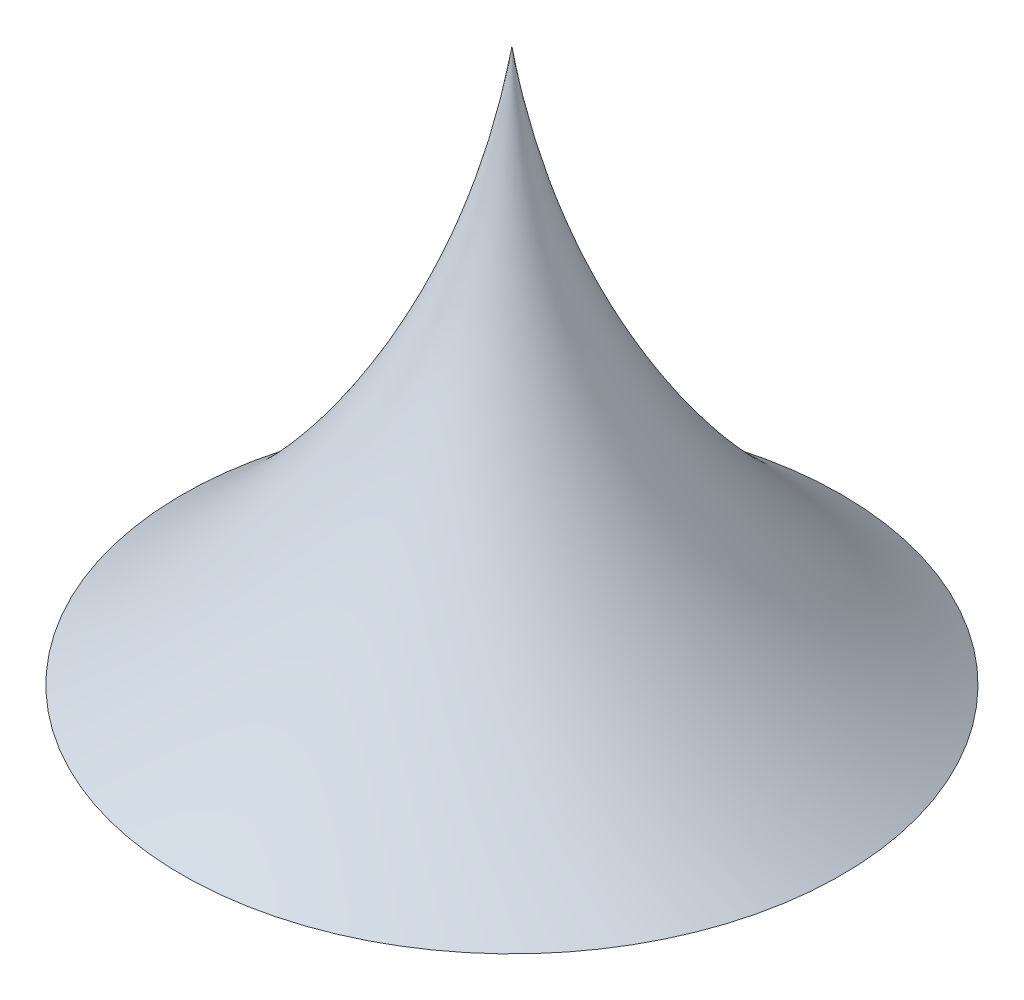
from build123d import *

# Parameters (mm, degrees)
SKETCH4_W               = 141.009584828
SKETCH4_H               = 12
CUT_EXTRUDE1_DEPTH      = 53.911904977
CUT_EXTRUDE1_DEPTH_BACK = 53.911904977
CUT_EXTRUDE2_DEPTH      = 20


with BuildPart() as part:
    # Sketch3 → Revolve2 (revolve)
    with BuildSketch(Plane.XY):
        with BuildLine():
            Line((0, 0), (0, 60.774821803))
            ThreePointArc((0, 60.774821803), (17.600685917, 22.677819891), (52.911904877, 0))
            Line((52.911904877, 0), (0, 0))
        make_face()
    revolve(axis=Axis((0, 0, 0), (0, 1, 0)))

    # Sketch4 → Cut-Extrude1 (cut, two sides)
    with BuildSketch(Plane(origin=(0, 0, 0), x_dir=(0, 0, -1), z_dir=(1, 0, 0))) as cut_extrude1_sk:
        with Locations((0, 6)):
            Rectangle(SKETCH4_W, SKETCH4_H)
    extrude(amount=CUT_EXTRUDE1_DEPTH, mode=Mode.SUBTRACT)
    extrude(cut_extrude1_sk.sketch, amount=-CUT_EXTRUDE1_DEPTH_BACK, mode=Mode.SUBTRACT)

    # Sketch5 → Cut-Extrude2 (cut)
    with BuildSketch(Plane.XZ.offset(-12)):
        Polygon((-5.41643054, 4.942227588), (-6.988309913, -2.219652652), (-1.571879373, -7.16188024), (5.41643054, -4.942227588), (6.988309913, 2.219652652), (1.571879373, 7.16188024), align=None)
    extrude(amount=-CUT_EXTRUDE2_DEPTH, mode=Mode.SUBTRACT)


solid = part.part
